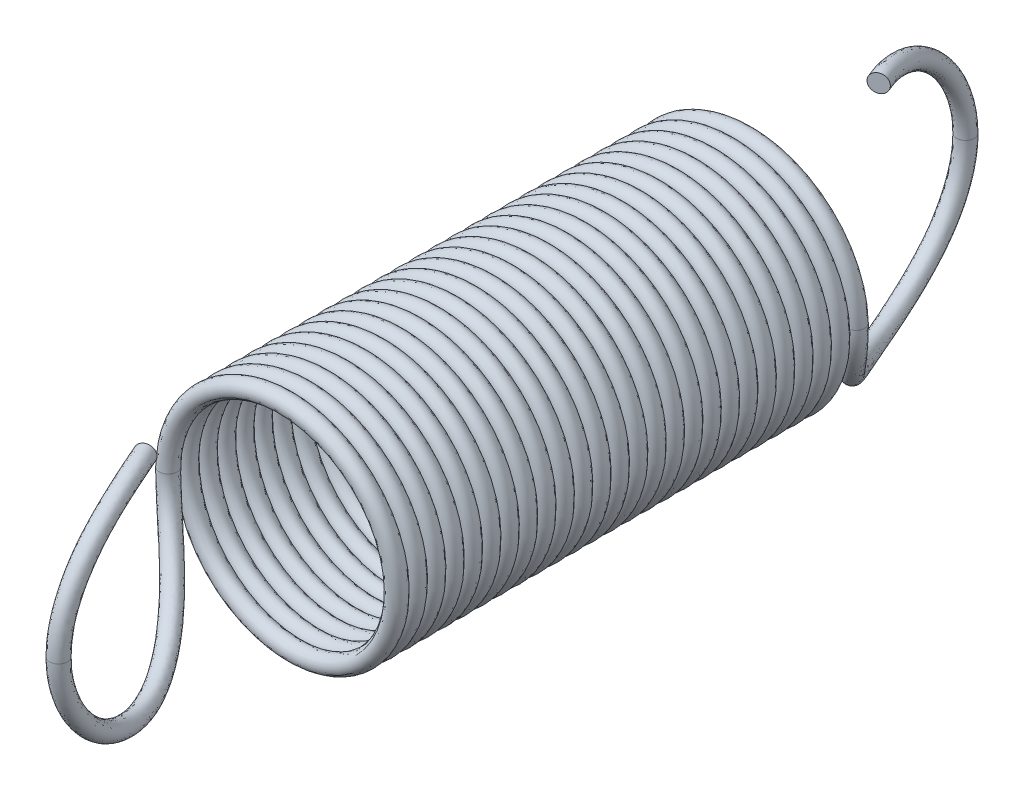
from build123d import *

# Parameters (mm, degrees)
SPRING_BODY_SWEEP_PITCH      = 0.309803922
SPRING_BODY_SWEEP_HEIGHT     = 7.9
SPRING_BODY_SWEEP_RADIUS     = 1.85
SKETCH4_R                    = 0.15
SKETCH7_R                    = 0.15
SPRING_HOOK_CIRPATTERN_COUNT = 2


with BuildPart() as part:
    # Spring Body Sweep: sweep along a helix
    with BuildLine() as spring_body_sweep_path:
        Helix(SPRING_BODY_SWEEP_PITCH, SPRING_BODY_SWEEP_HEIGHT, SPRING_BODY_SWEEP_RADIUS, center=(0, 0, 3.95), direction=(0, 0, -1))
    # Sketch4 → Spring Body Sweep (sweep)
    with BuildSketch(Plane(origin=(0, 0, 0), x_dir=(1, 0, 0), z_dir=(0, 1, 0))):
        with Locations((-1.85, -3.95)):
            Circle(SKETCH4_R)
    sweep(path=spring_body_sweep_path.line, is_frenet=True)

    # Spring Hook Sweep: sweep along a curve in space
    with BuildLine() as spring_hook_sweep_path:
        add(Edge.make_bspline(
            [(-1.85, 0, 3.95), (-1.85, -0.528140498, 3.95), (-1.550614583, -0.976088233, 4.169988407), (-0.980972011, -1.597724186, 4.771912718), (-0.680442249, -1.805567343, 5.179581119), (-0.229418643, -1.88220383, 6.119846466), (-0.093516706, -1.72357453, 6.646666392), (0.010292431, -1.038437907, 7.415301783), (0, -0.525139218, 7.65), (0, 0, 7.65)],
            knots=[0, 0, 0, 0, 0.25, 0.25, 0.5, 0.5, 0.75, 0.75, 1, 1, 1, 1], degree=3))
        add(Edge.make_bspline(
            [(0, 0, 7.65), (0, 0.497124297, 7.65), (0.008715354, 0.984915526, 7.440551094), (-0.076719259, 1.666764272, 6.739874112), (-0.187400538, 1.85, 6.25531772), (-0.386117482, 1.85, 5.8)],
            knots=[0, 0, 0, 0, 0.5, 0.5, 1, 1, 1, 1], degree=3))
    # Sketch7 → Spring Hook Sweep (sweep)
    with BuildSketch(Plane.XZ):
        with Locations((-1.85, 3.95)):
            Circle(SKETCH7_R)
    spring_hook_sweep = sweep(path=spring_hook_sweep_path.line)

    # Spring Hook CirPattern: Spring Hook Sweep ×2 about axis
    spring_hook_cirpattern_axis = Axis((0, 2.540341184, 0), (0, -1, 0))
    for i in range(1, SPRING_HOOK_CIRPATTERN_COUNT):
        add(spring_hook_sweep.rotate(spring_hook_cirpattern_axis, i * 360 / SPRING_HOOK_CIRPATTERN_COUNT))


solid = part.part
